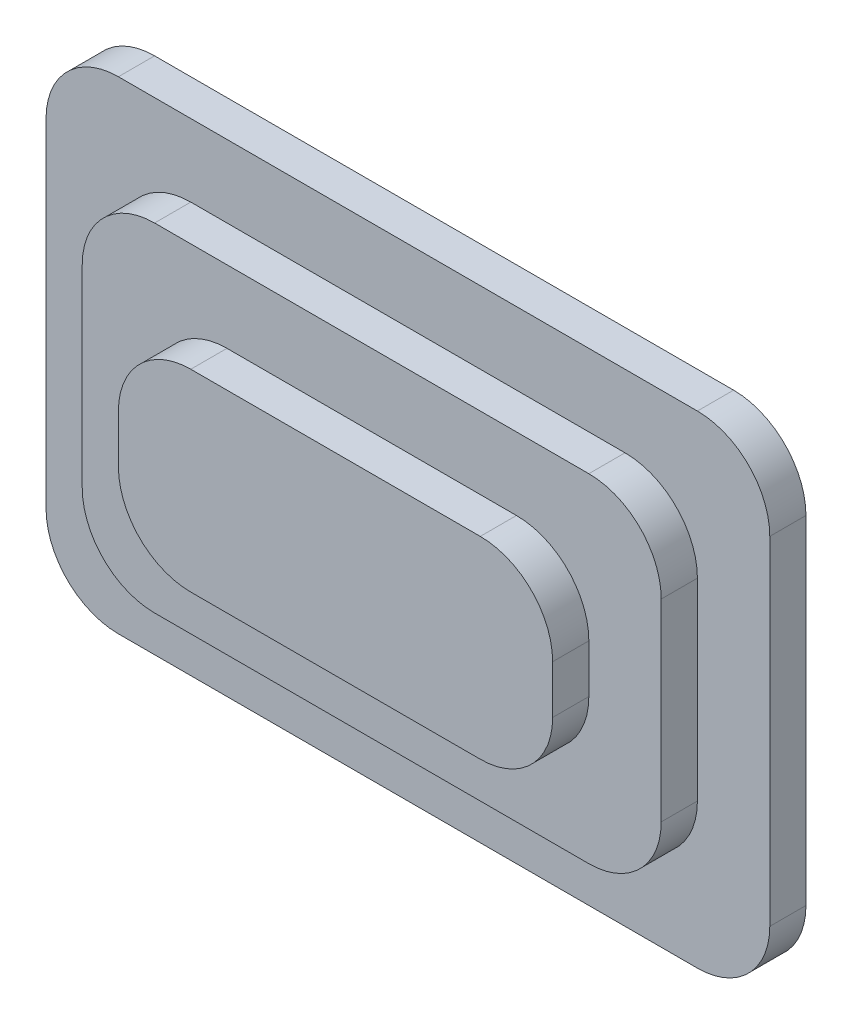
from build123d import *

# Parameters (mm, degrees)
SKETCH2_W           = 300
SKETCH2_H           = 200
BOSS_EXTRUDE1_DEPTH = 15
SKETCH3_W           = 240
SKETCH3_H           = 140
BOSS_EXTRUDE2_DEPTH = 15
SKETCH4_W           = 180
SKETCH4_H           = 80
BOSS_EXTRUDE3_DEPTH = 15
FILLET1_R           = 30
FILLET2_R           = 30
FILLET3_R           = 30
SCALE2_SCALE        = 2.5


with BuildPart() as part:
    # Sketch2 → Boss-Extrude1 (new body)
    with BuildSketch(Plane.XY):
        Rectangle(SKETCH2_W, SKETCH2_H)
    extrude(amount=BOSS_EXTRUDE1_DEPTH)

    # Sketch3 → Boss-Extrude2 (add)
    with BuildSketch(Plane.XY.offset(15)):
        Rectangle(SKETCH3_W, SKETCH3_H)
    extrude(amount=BOSS_EXTRUDE2_DEPTH)

    # Sketch4 → Boss-Extrude3 (add)
    with BuildSketch(Plane.XY.offset(30)):
        Rectangle(SKETCH4_W, SKETCH4_H)
    extrude(amount=BOSS_EXTRUDE3_DEPTH)

    # Fillet1
    fillet1_edges = [part.edges().sort_by_distance(p)[0] for p in [
        (-90, 40, 37.5),
        (-90, -40, 37.5),
        (90, -40, 37.5),
        (90, 40, 37.5),
    ]]
    fillet(fillet1_edges, radius=FILLET1_R)

    # Fillet2
    fillet2_edges = [part.edges().sort_by_distance(p)[0] for p in [
        (-120, 70, 22.5),
        (-120, -70, 22.5),
        (120, -70, 22.5),
        (120, 70, 22.5),
    ]]
    fillet(fillet2_edges, radius=FILLET2_R)

    # Fillet3
    fillet3_edges = [part.edges().sort_by_distance(p)[0] for p in [
        (150, -100, 7.5),
        (-150, -100, 7.5),
        (-150, 100, 7.5),
        (150, 100, 7.5),
    ]]
    fillet(fillet3_edges, radius=FILLET3_R)


with BuildPart() as part_1:
    # Scale2: scaled about (0, 0, 16.027771453)
    add(part.part.scale(SCALE2_SCALE).moved(Location((0, 0, -24.041657179))))


solid = part_1.part
